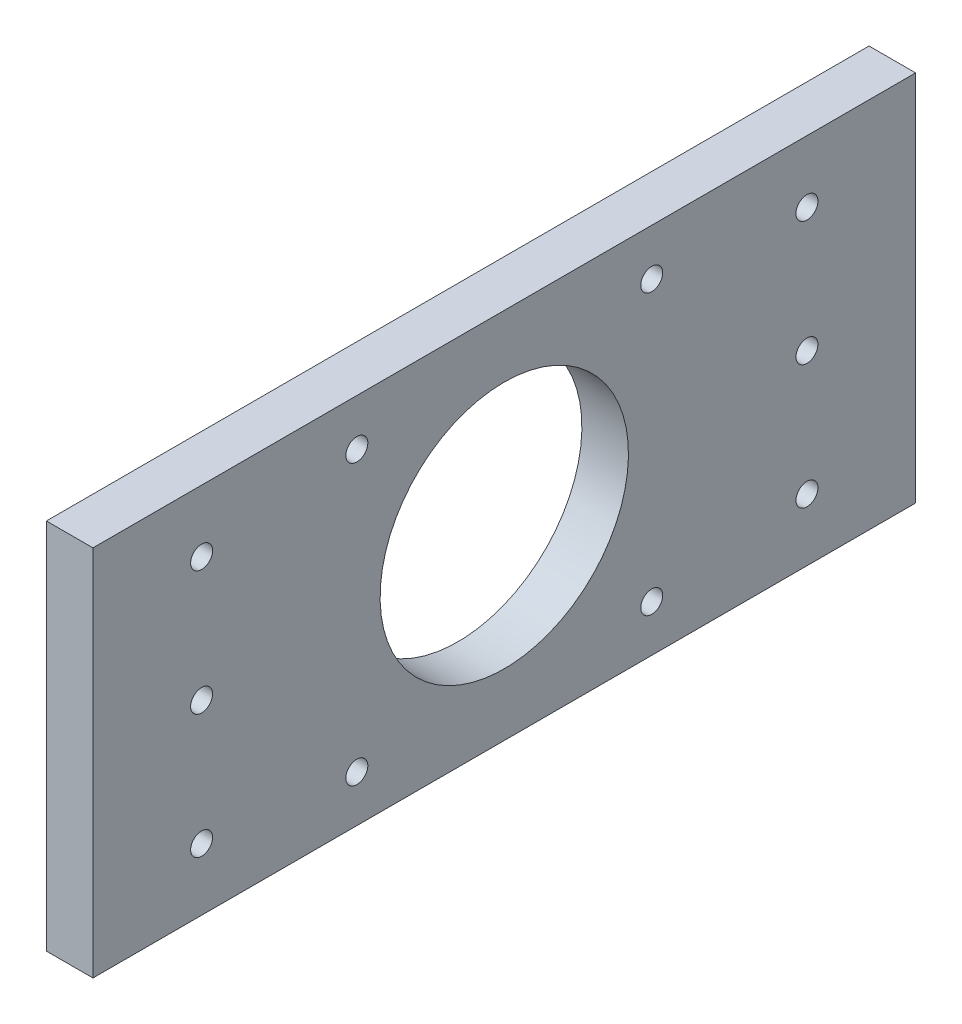
from build123d import *

# Parameters (mm, degrees)
SKETCH1_W             = 9.525
SKETCH1_H             = 76.2
BOSS_EXTRUDE1_DEPTH   = 168.275
F_8_CLEARANCE_HOLE1_D = 4.4958
F_8_CLEARANCE_HOLE2_D = 4.4958
SKETCH6_R             = 25.4
CUT_EXTRUDE1_DEPTH    = 10.525


with BuildPart() as part:
    # Sketch1 → Boss-Extrude1 (new body)
    with BuildSketch(Plane.XY):
        Rectangle(SKETCH1_W, SKETCH1_H)
    extrude(amount=BOSS_EXTRUDE1_DEPTH)

    # #8 Clearance Hole1 (through all)
    with Locations(Plane(origin=(4.7625, 0, 0), x_dir=(0, 0, -1), z_dir=(1, 0, 0))):
        with Locations((-146.05, 25.4), (-146.05, 0), (-146.05, -25.4), (-22.225, 25.4), (-22.225, 0), (-22.225, -25.4)):
            Hole(F_8_CLEARANCE_HOLE1_D / 2)

    # #8 Clearance Hole2 (through all)
    with Locations(Plane(origin=(4.7625, 0, 0), x_dir=(0, 0, -1), z_dir=(1, 0, 0))):
        with Locations((-114.3, 28.575), (-53.975, 28.575), (-53.975, -28.575), (-114.3, -28.575)):
            Hole(F_8_CLEARANCE_HOLE2_D / 2)

    # Sketch6 → Cut-Extrude1 (cut, through all)
    with BuildSketch(Plane(origin=(4.7625, 0, 0), x_dir=(0, 0, -1), z_dir=(1, 0, 0))):
        with Locations(Location((-84.1375, 0, 0), (0, 0, 90))):  # turned: the seam where the file's is
            Circle(SKETCH6_R)
    extrude(amount=-CUT_EXTRUDE1_DEPTH, mode=Mode.SUBTRACT)


solid = part.part
